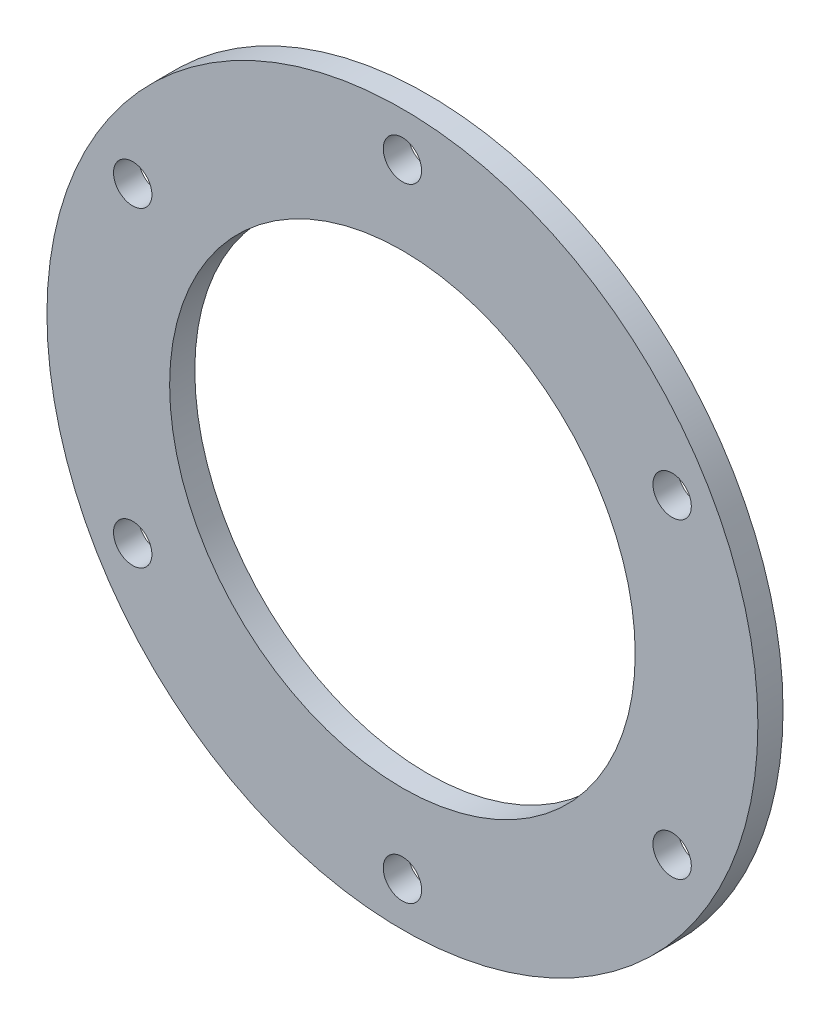
from build123d import *

# Parameters (mm, degrees)
SKETCH_1_R          = 28.25
SKETCH_1_R_2        = 18.5
EXTRUDE_1_DEPTH     = 2
SKETCH_2_R          = 1.525
CUT_EXTRUDE_1_DEPTH = 2


with BuildPart() as part:
    # 草图1 → 凸台-拉伸1 (new body)
    with BuildSketch(Plane.XY):
        Circle(SKETCH_1_R)
        Circle(SKETCH_1_R_2, mode=Mode.SUBTRACT)
    extrude(amount=EXTRUDE_1_DEPTH)

    # 草图2 → 切除-拉伸1 (cut)
    with BuildSketch(Plane.XY.offset(2)):
        with Locations((0, 24.75)):
            Circle(SKETCH_2_R)
        with Locations((21.434128744, 12.375)):
            Circle(SKETCH_2_R)
        with Locations((21.434128744, -12.375)):
            Circle(SKETCH_2_R)
        with Locations((0, -24.75)):
            Circle(SKETCH_2_R)
        with Locations((-21.434128744, -12.375)):
            Circle(SKETCH_2_R)
        with Locations((-21.434128744, 12.375)):
            Circle(SKETCH_2_R)
    extrude(amount=-CUT_EXTRUDE_1_DEPTH, mode=Mode.SUBTRACT)


solid = part.part
